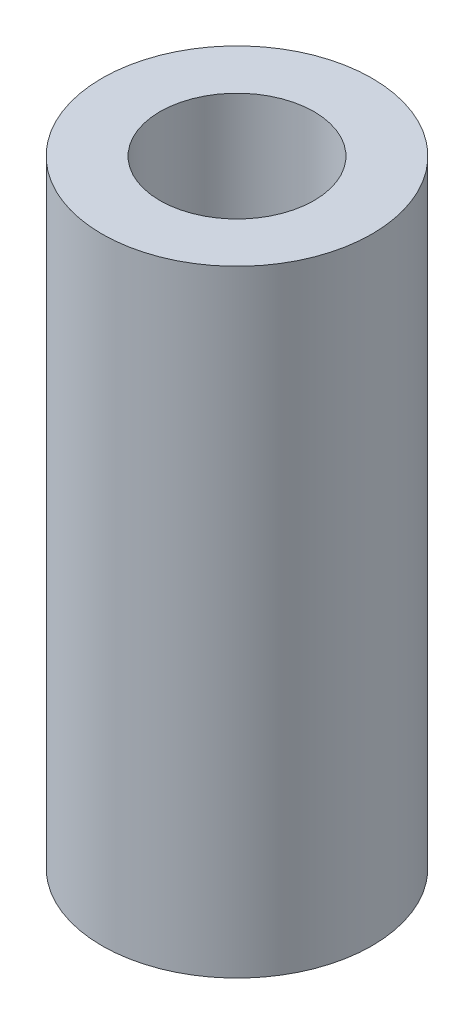
from build123d import *

# Parameters (mm, degrees)
SKETCH1_R           = 5.5626
SKETCH1_R_2         = 3.175
BOSS_EXTRUDE1_DEPTH = 25.4


with BuildPart() as part:
    # Sketch1 → Boss-Extrude1 (new body)
    with BuildSketch(Plane(origin=(0, 0, 0), x_dir=(1, 0, 0), z_dir=(0, 1, 0))):
        with Locations(Location((0, 0, 0), (0, 0, 270))):  # turned: the seam where the file's is
            Circle(SKETCH1_R)
        with Locations(Location((0, 0, 0), (0, 0, 270))):  # turned: the seam where the file's is
            Circle(SKETCH1_R_2, mode=Mode.SUBTRACT)
    extrude(amount=BOSS_EXTRUDE1_DEPTH)


solid = part.part
